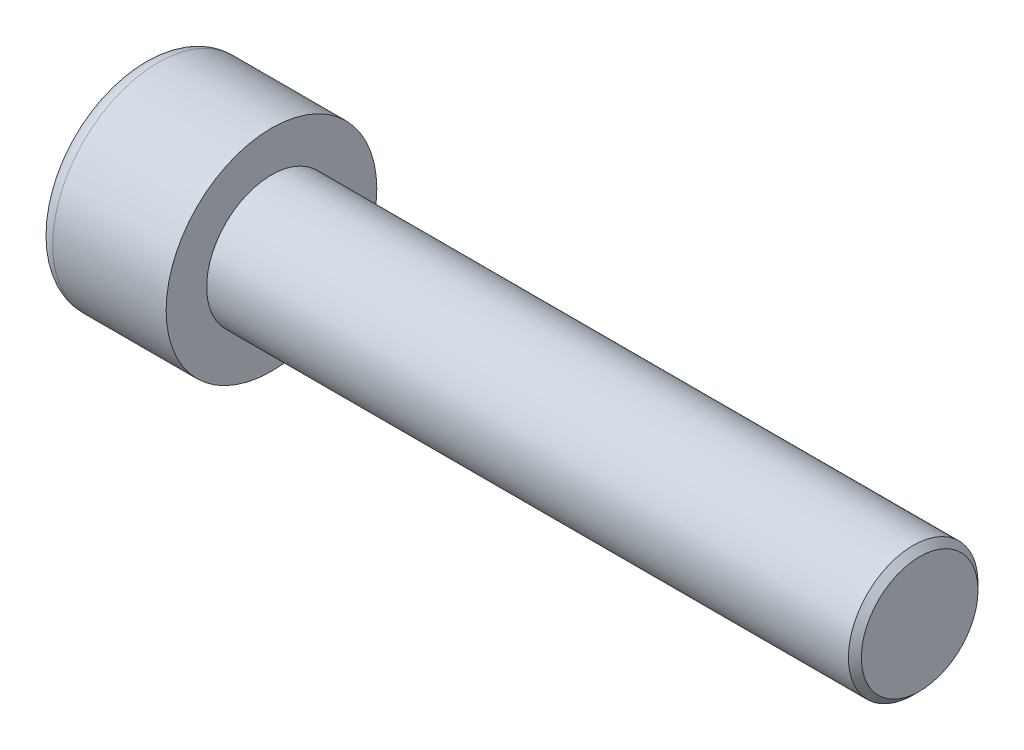
from build123d import *

# Parameters (mm, degrees)
SKETCH1_R           = 6.5
BASEHEAD_DEPTH      = 8
SKETCH2_R           = 4
BASEBODY_DEPTH      = 40
HEXAGONSOCKET_DEPTH = 4
TOPFILLET_R         = 1
CHAMFER1_SIZE       = 0.4


with BuildPart() as part:
    # Sketch1 → BaseHead (new body)
    with BuildSketch(Plane(origin=(0, 0, 0), x_dir=(0, 0, -1), z_dir=(1, 0, 0))):
        Circle(SKETCH1_R)
    extrude(amount=BASEHEAD_DEPTH)

    # Sketch2 → BaseBody (add)
    with BuildSketch(Plane(origin=(8, 0, 0), x_dir=(0, 0, -1), z_dir=(1, 0, 0))):
        Circle(SKETCH2_R)
    extrude(amount=BASEBODY_DEPTH)

    # Sketch3 → HexagonSocket (cut)
    with BuildSketch(Plane(origin=(0, 0, 0), x_dir=(0, 0, -1), z_dir=(1, 0, 0))):
        Polygon((3.464101615, 0), (1.732050808, 3), (-1.732050808, 3), (-3.464101615, 0), (-1.732050808, -3), (1.732050808, -3), align=None)
    extrude(amount=HEXAGONSOCKET_DEPTH, mode=Mode.SUBTRACT)

    # Sketch4 → Cut-Revolve1 (revolve, cut)
    with BuildSketch(Plane(origin=(-4.19613823, 0.75, 0), x_dir=(-1, 0, 0), z_dir=(0, 0, 1))):
        Polygon((-8.19613823, 3.75), (-9.928189037, 0.75), (-8.19613823, 0.75), align=None)
    revolve(axis=Axis((0.838992387, 0, 0), (-1, 0, 0)), mode=Mode.SUBTRACT)

    # TopFillet
    topfillet_edges = [part.edges().sort_by_distance(p)[0] for p in [
        (0, 0, 6.5),
    ]]
    fillet(topfillet_edges, radius=TOPFILLET_R)

    # Chamfer1
    chamfer1_edges = [part.edges().sort_by_distance(p)[0] for p in [
        (48, 0, 4),
    ]]
    chamfer(chamfer1_edges, length=CHAMFER1_SIZE)


solid = part.part
